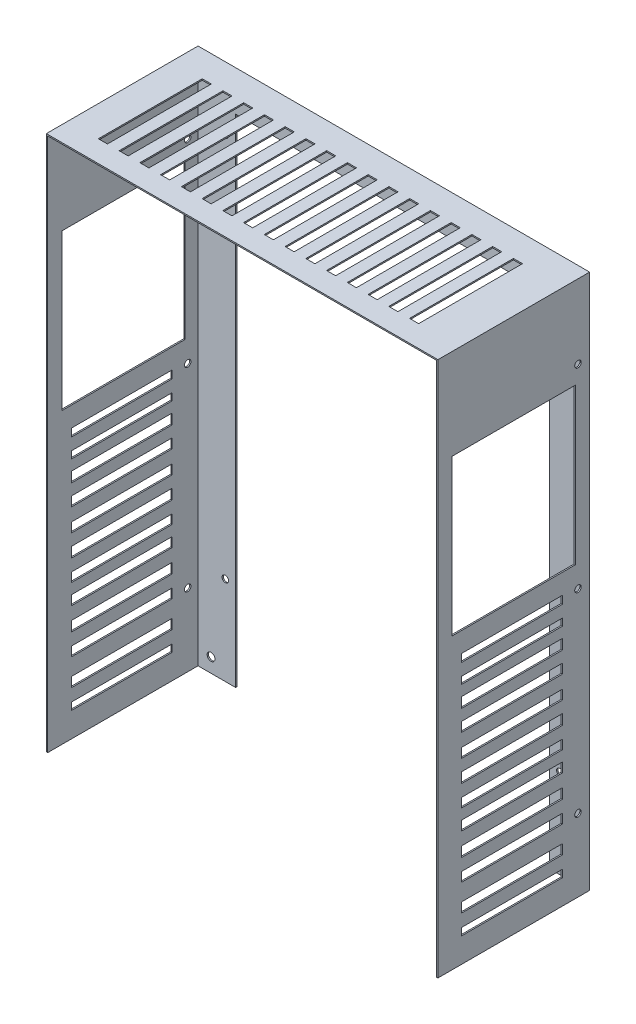
from build123d import *

# Parameters (mm, degrees)
SALIENTE_EXTRUIR1_DEPTH = 116
SALIENTE_EXTRUIR2_DEPTH = 1
CROQUIS4_R              = 2.5
CORTAR_EXTRUIR1_DEPTH   = 1
CROQUIS8_W              = 77.646192771
CROQUIS8_H              = 5.972784059
CROQUIS8_H_2            = 5.429803691
CROQUIS8_H_3            = 7.873215351
CROQUIS8_H_4            = 7.330234982
CROQUIS8_H_5            = 7.058744797
CROQUIS8_H_6            = 7.74799772
CROQUIS8_H_7            = 7.21365305
CROQUIS8_H_8            = 7.480825385
CROQUIS8_H_9            = 5.610619039
CORTAR_EXTRUIR3_DEPTH   = 302
CROQUIS9_W              = 7
CROQUIS9_H              = 80.105332856
CORTAR_EXTRUIR4_DEPTH   = 1
CROQUIS10_W             = 7
CROQUIS10_H             = 80.105332856
CORTAR_EXTRUIR5_DEPTH   = 1
SALIENTE_EXTRUIR4_DEPTH = 1
CROQUIS12_W             = 95
CROQUIS12_H             = 120
CORTAR_EXTRUIR6_DEPTH   = 302
CROQUIS13_R             = 3
CORTAR_EXTRUIR7_DEPTH   = 1
CROQUIS14_R             = 2.5
CORTAR_EXTRUIR8_DEPTH   = 302


with BuildPart() as part:
    # Croquis1 → Saliente-Extruir1 (new body)
    with BuildSketch(Plane.XY):
        Polygon((-301, 1), (-301, 0), (-302, 0), (-302, 413), (0, 413), (0, 0), (-1, 0), (-1, 1), (-1, 412), (-301, 412), align=None)
    extrude(amount=SALIENTE_EXTRUIR1_DEPTH)

    # Croquis8 → Cortar-Extruir3 (cut)
    with BuildSketch(Plane.ZY.offset(302)):
        with Locations((58.817511247, 204.636952511)):
            Rectangle(CROQUIS8_W, CROQUIS8_H)
        with Locations((58.817511247, 189.704992363)):
            Rectangle(CROQUIS8_W, CROQUIS8_H_2)
        with Locations((58.817511247, 174.908777307)):
            Rectangle(CROQUIS8_W, CROQUIS8_H_3)
        with Locations((58.817511247, 158.619366236)):
            Rectangle(CROQUIS8_W, CROQUIS8_H_4)
        with Locations((58.817511247, 141.243994427)):
            Rectangle(CROQUIS8_W, CROQUIS8_H_4)
        with Locations((58.817511247, 124.683093172)):
            Rectangle(CROQUIS8_W, CROQUIS8_H_3)
        with Locations((58.817511247, 107.986446824)):
            Rectangle(CROQUIS8_W, CROQUIS8_H_5)
        with Locations((58.817511247, 92.647251399)):
            Rectangle(CROQUIS8_W, CROQUIS8_H_4)
        with Locations((58.817511247, 75.255702304)):
            Rectangle(CROQUIS8_W, CROQUIS8_H_6)
        with Locations((58.817511247, 58.423845187)):
            Rectangle(CROQUIS8_W, CROQUIS8_H_7)
        with Locations((58.817511247, 37.985161546)):
            Rectangle(CROQUIS8_W, CROQUIS8_H_8)
        with Locations((58.817511247, 21.821235267)):
            Rectangle(CROQUIS8_W, CROQUIS8_H_9)
    extrude(amount=-CORTAR_EXTRUIR3_DEPTH, mode=Mode.SUBTRACT)

    # Croquis9 → Cortar-Extruir4 (cut)
    with BuildSketch(Plane(origin=(0, 413, 0), x_dir=(1, 0, 0), z_dir=(0, 1, 0))):
        with Locations((-275.000988129, -59.335747211)):
            Rectangle(CROQUIS9_W, CROQUIS9_H)
        with Locations((-259.000988129, -59.335747211)):
            Rectangle(CROQUIS9_W, CROQUIS9_H)
        with Locations((-243.000988129, -59.335747211)):
            Rectangle(CROQUIS9_W, CROQUIS9_H)
        with Locations((-227.000988129, -59.335747211)):
            Rectangle(CROQUIS9_W, CROQUIS9_H)
        with Locations((-211.000988129, -59.335747211)):
            Rectangle(CROQUIS9_W, CROQUIS9_H)
        with Locations((-195.000988129, -59.335747211)):
            Rectangle(CROQUIS9_W, CROQUIS9_H)
        with Locations((-179.000988129, -59.335747211)):
            Rectangle(CROQUIS9_W, CROQUIS9_H)
        with Locations((-163.000988129, -59.335747211)):
            Rectangle(CROQUIS9_W, CROQUIS9_H)
    extrude(amount=-CORTAR_EXTRUIR4_DEPTH, mode=Mode.SUBTRACT)

    # Croquis10 → Cortar-Extruir5 (cut)
    with BuildSketch(Plane(origin=(0, 413, 0), x_dir=(1, 0, 0), z_dir=(0, 1, 0))):
        with Locations((-147.000988129, -59.335747211)):
            Rectangle(CROQUIS10_W, CROQUIS10_H)
        with Locations((-131.000988129, -59.335747211)):
            Rectangle(CROQUIS10_W, CROQUIS10_H)
        with Locations((-115.000988129, -59.335747211)):
            Rectangle(CROQUIS10_W, CROQUIS10_H)
        with Locations((-99.000988129, -59.335747211)):
            Rectangle(CROQUIS10_W, CROQUIS10_H)
        with Locations((-83.000988129, -59.335747211)):
            Rectangle(CROQUIS10_W, CROQUIS10_H)
        with Locations((-67.000988129, -59.335747211)):
            Rectangle(CROQUIS10_W, CROQUIS10_H)
        with Locations((-51.000988129, -59.335747211)):
            Rectangle(CROQUIS10_W, CROQUIS10_H)
        with Locations((-35.000988129, -59.335747211)):
            Rectangle(CROQUIS10_W, CROQUIS10_H)
    extrude(amount=-CORTAR_EXTRUIR5_DEPTH, mode=Mode.SUBTRACT)



with BuildPart() as body_2:
    # Croquis2 → Saliente-Extruir2 (new body)
    with BuildSketch(Plane(origin=(0, 0, 0), x_dir=(-1, 0, 0), z_dir=(0, 0, -1))):
        Polygon((30, 383), (272, 383), (272, 0), (301, 0), (301, 412), (1, 412), (1, 0), (30, 0), align=None)
    extrude(amount=SALIENTE_EXTRUIR2_DEPTH)

    # Croquis4 → Cortar-Extruir1 (cut)
    with BuildSketch(Plane(origin=(0, 0, -1), x_dir=(-1, 0, 0), z_dir=(0, 0, -1))):
        with Locations((22, 365.5)):
            Circle(CROQUIS4_R)
        with Locations((22, 68.5)):
            Circle(CROQUIS4_R)
        with Locations((280, 68.5)):
            Circle(CROQUIS4_R)
        with Locations((280, 365.5)):
            Circle(CROQUIS4_R)
    extrude(amount=-CORTAR_EXTRUIR1_DEPTH, mode=Mode.SUBTRACT)


with BuildPart() as part_1:
    add(part.part)

    add(body_2.part)  # Saliente-Extruir4 merges body 2
    # Croquis11 → Saliente-Extruir4 (add)
    with BuildSketch(Plane(origin=(0, 0, 0), x_dir=(-1, 0, 0), z_dir=(0, 0, -1))):
        Polygon((301, 0), (302, 0), (302, 412), (302, 413), (301, 413), (1, 413), (0, 413), (0, 412), (0, 0), (1, 0), (1, 412), (301, 412), align=None)
    extrude(amount=SALIENTE_EXTRUIR4_DEPTH)

    # Croquis12 → Cortar-Extruir6 (cut)
    with BuildSketch(Plane(origin=(0, 0, 0), x_dir=(0, 0, -1), z_dir=(1, 0, 0))):
        with Locations((-57.5, 283)):
            Rectangle(CROQUIS12_W, CROQUIS12_H)
    extrude(amount=-CORTAR_EXTRUIR6_DEPTH, mode=Mode.SUBTRACT)

    # Croquis13 → Cortar-Extruir7 (cut)
    with BuildSketch(Plane.XY):
        with Locations((-291, 402)):
            Circle(CROQUIS13_R)
        with Locations((-291, 11)):
            Circle(CROQUIS13_R)
        with Locations((-11, 11)):
            Circle(CROQUIS13_R)
        with Locations((-11, 402)):
            Circle(CROQUIS13_R)
    extrude(amount=-CORTAR_EXTRUIR7_DEPTH, mode=Mode.SUBTRACT)

    # Croquis14 → Cortar-Extruir8 (cut)
    with BuildSketch(Plane.ZY.offset(302)):
        with Locations((8, 356)):
            Circle(CROQUIS14_R)
        with Locations((8, 56)):
            Circle(CROQUIS14_R)
        with Locations((8, 206)):
            Circle(CROQUIS14_R)
    extrude(amount=-CORTAR_EXTRUIR8_DEPTH, mode=Mode.SUBTRACT)


solid = part_1.part
